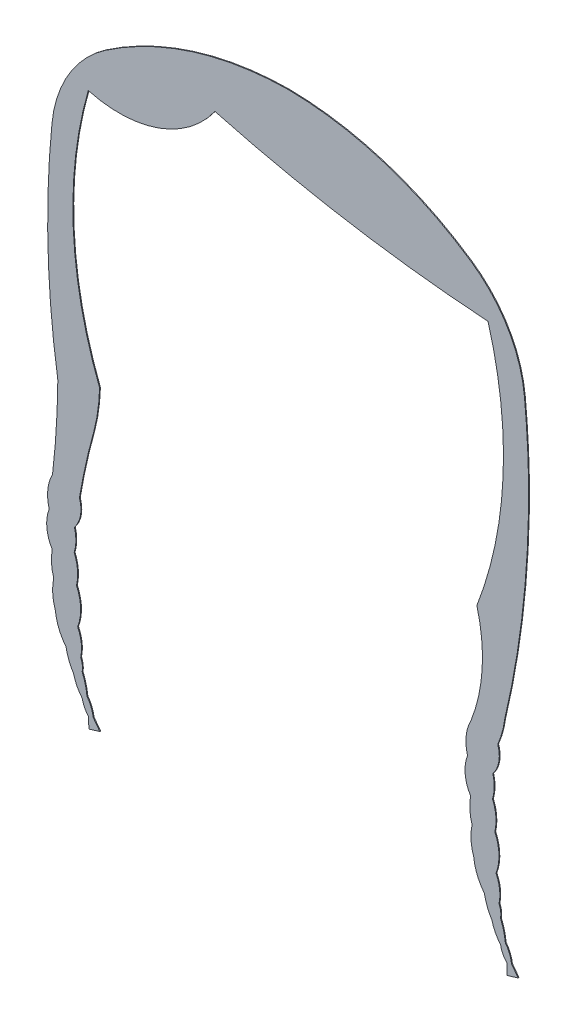
from build123d import *

# Parameters (mm, degrees)
SALIENTE_EXTRUIR1_DEPTH = 0.1


with BuildPart() as part:
    # Model → Saliente-Extruir1 (new body)
    with BuildSketch(Plane.XY):
        with BuildLine():
            Line((83.956301506, -17.166999348), (84.015376633, -18.477240051))
            Line((84.015376633, -18.477240051), (85.336602283, -18.077638007))
            Line((85.336602283, -18.077638007), (84.538223467, -17.008293358))
            ThreePointArc((84.538223467, -17.008293358), (84.278969465, -16.042382101), (83.786477348, -15.171951914))
            ThreePointArc((83.786477348, -15.171951914), (83.576571308, -14.005422888), (83.198659759, -12.8820203))
            ThreePointArc((83.198659759, -12.8820203), (83.21653602, -12.153238047), (83.021147285, -11.450908798))
            ThreePointArc((83.021147285, -11.450908798), (83.091174716, -9.918606089), (82.654557847, -8.448156791))
            ThreePointArc((82.654557847, -8.448156791), (83.012265392, -6.298296984), (82.511107342, -4.177284848))
            ThreePointArc((82.511107342, -4.177284848), (82.63621748, -2.505599358), (82.234450021, -0.878095799))
            ThreePointArc((82.234450021, -0.878095799), (82.435913685, 0.460640045), (82.268030876, 1.804000246))
            ThreePointArc((82.268030876, 1.804000246), (82.996051805, 3.402356573), (82.865109648, 5.153816414))
            ThreePointArc((82.865109648, 5.153816414), (83.401985842, 6.694986621), (83.724308061, 8.294846004))
            ThreePointArc((83.724308061, 8.294846004), (85.978479306, 21.570456798), (86.584690484, 35.022432042))
            ThreePointArc((86.584690484, 35.022432042), (86.416684054, 39.135370857), (86.088155048, 43.23860867))
            ThreePointArc((86.088155048, 43.23860867), (84.060345255, 49.407216919), (79.615503089, 54.140832704))
            ThreePointArc((79.615503089, 54.140832704), (69.080555659, 59.249963441), (57.51663409, 61.084098716))
            ThreePointArc((57.51663409, 61.084098716), (45.952712521, 59.249963441), (35.417765091, 54.140832704))
            ThreePointArc((35.417765091, 54.140832704), (30.972922925, 49.407216919), (28.945113132, 43.23860867))
            ThreePointArc((28.945113132, 43.23860867), (28.46242928, 29.95974371), (29.654838805, 16.72571946))
            ThreePointArc((29.654838805, 16.72571946), (29.473058184, 11.615593771), (29.015376633, 6.522759949))
            ThreePointArc((29.015376633, 6.522759949), (28.442846773, 4.643578134), (28.610136964, 2.6862512))
            ThreePointArc((28.610136964, 2.6862512), (28.323722373, 0.618533481), (28.978689788, -1.363512826))
            ThreePointArc((28.978689788, -1.363512826), (28.890519119, -2.843965116), (29.162248311, -4.30193504))
            ThreePointArc((29.162248311, -4.30193504), (29.034928035, -5.947952582), (29.360669993, -7.566432232))
            ThreePointArc((29.360669993, -7.566432232), (29.77476773, -9.238513166), (30.644216328, -10.725587717))
            ThreePointArc((30.644216328, -10.725587717), (30.987352099, -11.946605577), (31.558807946, -13.078888662))
            ThreePointArc((31.558807946, -13.078888662), (31.963393581, -14.170963904), (32.606401809, -15.141972807))
            ThreePointArc((32.606401809, -15.141972807), (32.871834994, -15.95176655), (33.355447957, -16.653435407))
            Line((33.355447957, -16.653435407), (33.414523084, -17.96367611))
            Line((33.414523084, -17.96367611), (34.735748735, -17.564074065))
            Line((34.735748735, -17.564074065), (33.937369918, -16.494729417))
            ThreePointArc((33.937369918, -16.494729417), (33.678115916, -15.52881816), (33.185623799, -14.658387973))
            ThreePointArc((33.185623799, -14.658387973), (32.97571776, -13.491858947), (32.59780621, -12.368456359))
            ThreePointArc((32.59780621, -12.368456359), (32.615682471, -11.639674106), (32.420293737, -10.937344857))
            ThreePointArc((32.420293737, -10.937344857), (32.490321167, -9.405042148), (32.053704298, -7.93459285))
            ThreePointArc((32.053704298, -7.93459285), (32.411411843, -5.784733043), (31.910253793, -3.663720907))
            ThreePointArc((31.910253793, -3.663720907), (32.035363932, -1.992035417), (31.633596472, -0.364531858))
            ThreePointArc((31.633596472, -0.364531858), (31.835060136, 0.974203986), (31.667177327, 2.317564187))
            ThreePointArc((31.667177327, 2.317564187), (32.395198256, 3.915920514), (32.2642561, 5.667380355))
            ThreePointArc((32.2642561, 5.667380355), (33.036563223, 9.618087334), (34.015376633, 13.522759949))
            ThreePointArc((34.015376633, 13.522759949), (34.500457554, 15.949651286), (34.706334447, 18.41596833))
            ThreePointArc((34.706334447, 18.41596833), (31.522529085, 33.538428771), (33.337993753, 48.885399624))
            ThreePointArc((33.337993753, 48.885399624), (41.857208532, 49.214409123), (48.657173595, 54.356951572))
            ThreePointArc((48.657173595, 54.356951572), (65.042417717, 50.813818289), (81.695137016, 48.885876802))
            ThreePointArc((81.695137016, 48.885876802), (83.511455819, 33.554448429), (80.338345767, 18.445408666))
            ThreePointArc((80.338345767, 18.445408666), (80.983262934, 12.168889843), (79.616230182, 6.009196008))
            ThreePointArc((79.616230182, 6.009196008), (79.043700322, 4.130014193), (79.210990513, 2.172687259))
            ThreePointArc((79.210990513, 2.172687259), (78.924575921, 0.10496954), (79.579543337, -1.877076767))
            ThreePointArc((79.579543337, -1.877076767), (79.491372668, -3.357529058), (79.763101859, -4.815498981))
            ThreePointArc((79.763101859, -4.815498981), (79.635781584, -6.461516523), (79.961523541, -8.079996173))
            ThreePointArc((79.961523541, -8.079996173), (80.375621279, -9.752077107), (81.245069877, -11.239151658))
            ThreePointArc((81.245069877, -11.239151658), (81.588205648, -12.460169518), (82.159661495, -13.592452603))
            ThreePointArc((82.159661495, -13.592452603), (82.56424713, -14.684527845), (83.207255358, -15.655536748))
            ThreePointArc((83.207255358, -15.655536748), (83.472688543, -16.465330491), (83.956301506, -17.166999348))
        make_face()
    extrude(amount=SALIENTE_EXTRUIR1_DEPTH)


solid = part.part
